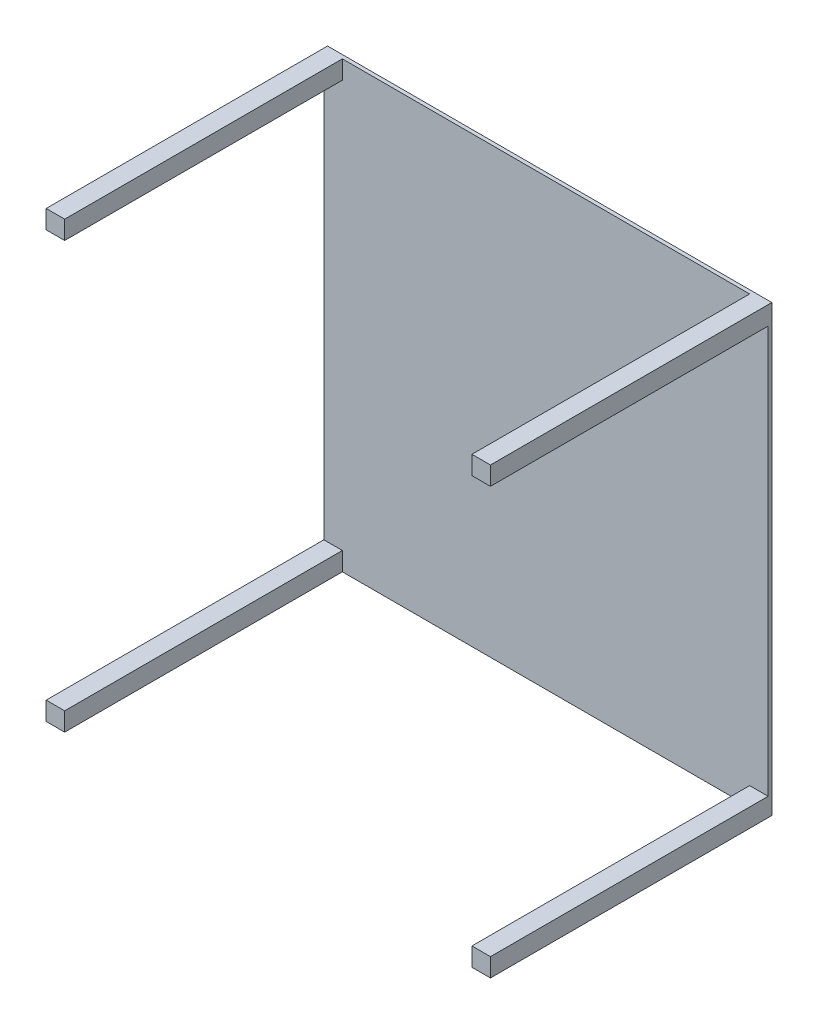
from build123d import *

# Parameters (mm, degrees)
SKETCH1_W           = 1200
SKETCH1_H           = 1200
BOSS_EXTRUDE1_DEPTH = 10
SKETCH2_W           = 50
SKETCH2_H           = 50
BOSS_EXTRUDE2_DEPTH = 750


with BuildPart() as part:
    # Sketch1 → Boss-Extrude1 (new body)
    with BuildSketch(Plane.XY):
        with Locations((-600, -600)):
            Rectangle(SKETCH1_W, SKETCH1_H)
    extrude(amount=BOSS_EXTRUDE1_DEPTH)

    # Sketch2 → Boss-Extrude2 (add)
    with BuildSketch(Plane.XY.offset(10)):
        with Locations((-1175, -1175)):
            Rectangle(SKETCH2_W, SKETCH2_H)
        with Locations((-1175, -25)):
            Rectangle(SKETCH2_W, SKETCH2_H)
        with Locations((-25, -1175)):
            Rectangle(SKETCH2_W, SKETCH2_H)
        with Locations((-25, -25)):
            Rectangle(SKETCH2_W, SKETCH2_H)
    extrude(amount=BOSS_EXTRUDE2_DEPTH)


solid = part.part
